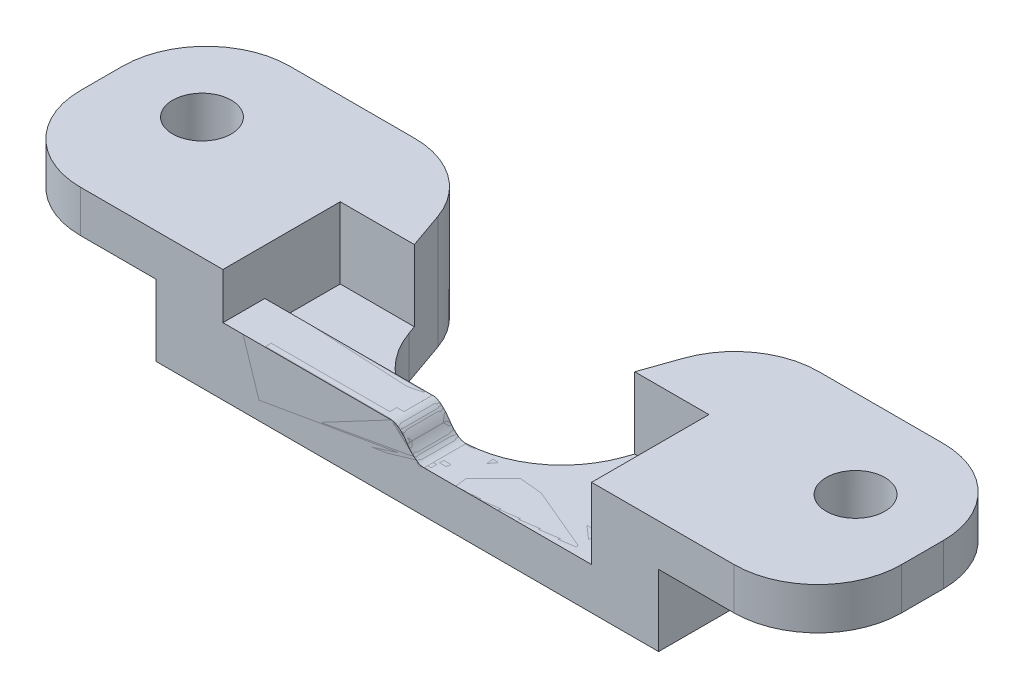
from build123d import *

# Parameters (mm, degrees)
EXTRUDE_1_DEPTH              = 5
EXTRUDE_2_DEPTH              = 5
SKETCH_3_R                   = 3.5
EXTRUDE_3_DEPTH              = 8.5
CUT_EXTRUDE_1_REACH          = 73.086
SKETCH_4_W                   = 19
SKETCH_4_H                   = 3.5
FILLET_5_R                   = 10
FILLET_6_R                   = 12
EXTRUDE_4_REACH              = 71.486
SKETCH_5_W                   = 5
SKETCH_5_H                   = 3
EXTRUDE_5_DEPTH              = 5
MM_TRANSITIONAL_0_AT_2_COUNT = 2
MM_TRANSITIONAL_0_AT_2_PITCH = 5
MM_TRANSITIONAL_0_AT_3_COUNT = 2
MM_TRANSITIONAL_0_AT_3_PITCH = 55
MM_TRANSITIONAL_0_AT_4_COUNT = 2
MM_TRANSITIONAL_0_AT_4_PITCH = 55.226805086


with BuildPart() as part:
    # 草图1 → 凸台-拉伸1 (new body)
    with BuildSketch(Plane.XY):
        with BuildLine():
            Line((0, 0), (0, 3))
            Line((0, 3), (15, 3))
            add(Edge.make_bspline(
                [(15, 3), (15.084020518, 3), (15.25421211, 2.98372688), (15.507820044, 2.911236723), (15.760073164, 2.791236035), (16.011273009, 2.624324039), (16.261740047, 2.410885471), (16.511438591, 2.15079543), (16.762076533, 1.845030055), (17, 1.5), (17.237923467, 1.154969945), (17.488561409, 0.84920457), (17.738259953, 0.589114529), (17.988726991, 0.375675961), (18.239926836, 0.208763965), (18.492179956, 0.088763277), (18.74578789, 0.01627312), (18.915979482, 0), (19, 0)],
                knots=[0, 0, 0, 0, 0.048331255, 0.098318483, 0.151463082, 0.209019894, 0.271980496, 0.341104305, 0.416965872, 0.5, 0.583034128, 0.658895695, 0.728019504, 0.790980106, 0.848536918, 0.901681517, 0.951668745, 1, 1, 1, 1], degree=3))
            Line((19, 0), (34, 0))
            Line((34, 0), (34, -5))
            Line((34, -5), (0, -5))
            Line((0, -5), (0, 0))
        make_face()
    extrude(amount=EXTRUDE_1_DEPTH)

    # 草图2 → 凸台-拉伸2 (add)
    with BuildSketch(Plane(origin=(0, 0, 0), x_dir=(1, 0, 0), z_dir=(0, 1, 0))):
        Polygon((-13, 20), (0, 20), (7, 0), (27, 0), (34, 20), (47, 20), (47, -5), (-13, -5), align=None)
    extrude(amount=-EXTRUDE_2_DEPTH)

    # 草图3 → 凸台-拉伸3 (add)
    with BuildSketch(Plane(origin=(0, 0, 0), x_dir=(1, 0, 0), z_dir=(0, 1, 0))):
        Polygon((-32, 20), (0, 20), (3.85, 9), (-5, 9), (-5, -5), (-32, -5), align=None)
        with Locations(Location((-22, 9.5, 0), (0, 0, 270))):
            Circle(SKETCH_3_R, mode=Mode.SUBTRACT)
        Polygon((30.15, 9), (34, 20), (66, 20), (66, -5), (39, -5), (39, 9), align=None)
        with Locations(Location((56, 9.5, 0), (0, 0, 90))):
            Circle(SKETCH_3_R, mode=Mode.SUBTRACT)
    extrude(amount=EXTRUDE_3_DEPTH)

    # 草图4 → 切除-拉伸1 (cut, up to next)
    with BuildSketch(Plane.XY.offset(5), mode=Mode.PRIVATE) as cut_extrude_1_sk1:
        with Locations((-22.5, 1.75)):
            Rectangle(SKETCH_4_W, SKETCH_4_H)
    cut_extrude_1_tool1 = extrude(cut_extrude_1_sk1.sketch, amount=-CUT_EXTRUDE_1_REACH, mode=Mode.PRIVATE) & part.part
    # 草图4 → 切除-拉伸1 (cut, up to next)
    with BuildSketch(Plane.XY.offset(5), mode=Mode.PRIVATE) as cut_extrude_1_sk2:
        with Locations((56.5, 1.75)):
            Rectangle(SKETCH_4_W, SKETCH_4_H)
    cut_extrude_1_tool2 = extrude(cut_extrude_1_sk2.sketch, amount=-CUT_EXTRUDE_1_REACH, mode=Mode.PRIVATE) & part.part
    add(cut_extrude_1_tool1.solids().sort_by_distance((-22.5, 1.75, 5))[0], mode=Mode.SUBTRACT)
    add(cut_extrude_1_tool2.solids().sort_by_distance((56.5, 1.75, 5))[0], mode=Mode.SUBTRACT)

    # 圆角5
    fillet_5_edges = [part.edges().sort_by_distance(p)[0] for p in [
        (0, 1.75, -20),
        (34, 1.75, -20),
        (-32, 6, -20),
        (-32, 6, 5),
        (66, 6, 5),
        (66, 6, -20),
    ]]
    fillet(fillet_5_edges, radius=FILLET_5_R)

    # 圆角6
    fillet_6_edges = [part.edges().sort_by_distance(p)[0] for p in [
        (7, -2.5, 0),
        (27, -2.5, 0),
    ]]
    fillet(fillet_6_edges, radius=FILLET_6_R)

    # 草图5 → 凸台-拉伸4 (add, up to next)
    with BuildSketch(Plane.ZY, mode=Mode.PRIVATE) as extrude_4_sk1:
        with Locations((2.5, 1.5)):
            Rectangle(SKETCH_5_W, SKETCH_5_H)
    extrude_4_tool1 = extrude(extrude_4_sk1.sketch, amount=EXTRUDE_4_REACH, mode=Mode.PRIVATE) - part.part
    add(extrude_4_tool1.solids().sort_by_distance((0, 1.5, 2.5))[0])

    # 草图9 → 大小mm Transitional 暗销孔0 (revolve, cut)
    with BuildSketch(Plane(origin=(44.5, -5, -7.000000033), x_dir=(0, 0, -1), z_dir=(1, 0, 0))):
        Polygon((0, 0), (0, 5.600860619), (1, 5), (1, 0), align=None)
    mm_transitional_0 = revolve(axis=Axis((44.5, -11.35, -7.000000033), (0, 1, 0)), mode=Mode.SUBTRACT)

    # 大小mm Transitional 暗销孔0 at 2: 大小mm Transitional 暗销孔0 ×2
    with Locations(*[(0, 0, -i * MM_TRANSITIONAL_0_AT_2_PITCH) for i in range(1, MM_TRANSITIONAL_0_AT_2_COUNT)]):
        add(mm_transitional_0, mode=Mode.SUBTRACT)

    # 大小mm Transitional 暗销孔0 at 3: 大小mm Transitional 暗销孔0 ×2
    with Locations(*[(-i * MM_TRANSITIONAL_0_AT_3_PITCH, 0, 0) for i in range(1, MM_TRANSITIONAL_0_AT_3_COUNT)]):
        add(mm_transitional_0, mode=Mode.SUBTRACT)

    # 大小mm Transitional 暗销孔0 at 4: 大小mm Transitional 暗销孔0 ×2
    with Locations(*[Vector(-0.9958932064677039, 0, -0.09053574604251886) * (i * MM_TRANSITIONAL_0_AT_4_PITCH) for i in range(1, MM_TRANSITIONAL_0_AT_4_COUNT)]):
        add(mm_transitional_0, mode=Mode.SUBTRACT)


with BuildPart() as body_2:
    # 草图7 → 凸台-拉伸5 (new body)
    with BuildSketch(Plane.XY):
        with BuildLine():
            add(Edge.make_bspline(
                [(0, -5), (11.333333333, -5), (22.666666667, -5), (34, -5), (34.75, -5), (35.5, -5), (36.25, -5), (36.333333333, -5), (36.5, -5), (36.75, -5), (36.916666667, -5), (37, -5), (37.085177062, -5), (37.255531185, -5), (37.511374058, -4.951599022), (37.67635735, -4.908276535), (37.757529961, -4.882466864), (40.584958925, -3.983456605), (40.584958925, -1.016543395), (37.757529961, -0.117533136), (37.67635735, -0.091723465), (37.511374058, -0.048400978), (37.255531185, 0), (37.085177062, 0), (37, 0), (36.916666667, 0), (36.75, 0), (36.5, 0), (36.333333333, 0), (36.25, 0), (35.5, 0), (34.75, 0), (34, 0), (29.423914321, 0), (24.847828642, 0), (20.271742963, 0), (20.129177345, 0), (19.844046109, 0), (19.416349256, 0), (19.13121802, 0), (18.988652402, 0), (18.899425687, 0), (18.720972257, 0), (18.443548085, 0.080405029), (18.292751559, 0.175830572), (18.217353296, 0.223543343), (18.172514092, 0.251918038), (18.082835683, 0.308667427), (17.956306563, 0.406511786), (17.874611554, 0.474305988), (17.834660313, 0.509228415), (17.805986227, 0.534293186), (17.68905163, 0.640370713), (17.488561409, 0.84920457), (17.237923467, 1.154969945), (17, 1.5), (16.762076533, 1.845030055), (16.511438591, 2.15079543), (16.31094837, 2.359629287), (16.194013773, 2.465706814), (16.165339687, 2.490771585), (16.125388446, 2.525694012), (16.043693437, 2.593488214), (15.917164317, 2.691332573), (15.827485908, 2.748081962), (15.782646704, 2.776456657), (15.707248441, 2.824169428), (15.556451915, 2.919594971), (15.279027743, 3), (15.100574313, 3), (15.011347598, 3), (14.86878198, 3), (14.583650744, 3), (14.155953891, 3), (13.870822655, 3), (13.728257037, 3), (9.152171358, 3), (4.576085679, 3), (0, 3), (-0.75, 3), (-1.5, 3), (-2.25, 3), (-2.333333333, 3), (-2.5, 3), (-2.75, 3), (-2.916666667, 3), (-3, 3), (-3.085382499, 3), (-3.256147498, 3), (-3.512422936, 2.969801398), (-3.681082298, 2.942514055), (-3.764889213, 2.926187017), (-9.340137732, 1.840032069), (-9.340137732, -3.840032069), (-3.764889213, -4.926187017), (-3.681082298, -4.942514055), (-3.512422936, -4.969801398), (-3.256147498, -5), (-3.085382499, -5), (-3, -5), (-2.916666667, -5), (-2.75, -5), (-2.5, -5), (-2.333333333, -5), (-2.25, -5), (-1.5, -5), (-0.75, -5), (0, -5)],
                knots=[0, 0, 0, 0, 0.350984847, 0.350984847, 0.350984847, 0.374211786, 0.374211786, 0.374211786, 0.376792557, 0.379373328, 0.381954099, 0.381954099, 0.381954099, 0.384591968, 0.387229838, 0.389867708, 0.389867708, 0.389867708, 0.439056518, 0.439056518, 0.439056518, 0.441694388, 0.444332258, 0.446970127, 0.446970127, 0.446970127, 0.449550898, 0.452131669, 0.45471244, 0.45471244, 0.45471244, 0.477939379, 0.477939379, 0.477939379, 0.619657326, 0.619657326, 0.619657326, 0.624072476, 0.628487627, 0.632902777, 0.632902777, 0.632902777, 0.635666062, 0.638429346, 0.641192631, 0.641192631, 0.641192631, 0.642835951, 0.644479271, 0.646122591, 0.646122591, 0.646122591, 0.647302046, 0.651011173, 0.655081842, 0.659537385, 0.663992927, 0.668063596, 0.671772723, 0.672952178, 0.672952178, 0.672952178, 0.674595498, 0.676238818, 0.677882138, 0.677882138, 0.677882138, 0.680645423, 0.683408707, 0.686171992, 0.686171992, 0.686171992, 0.690587142, 0.695002293, 0.699417443, 0.699417443, 0.699417443, 0.84113539, 0.84113539, 0.84113539, 0.864362329, 0.864362329, 0.864362329, 0.8669431, 0.869523871, 0.872104642, 0.872104642, 0.872104642, 0.874748874, 0.877393106, 0.880037338, 0.880037338, 0.880037338, 0.961098053, 0.961098053, 0.961098053, 0.963742285, 0.966386517, 0.969030749, 0.969030749, 0.969030749, 0.97161152, 0.974192291, 0.976773062, 0.976773062, 0.976773062, 1, 1, 1, 1], degree=3, weights=[1, 1, 1, 1, 1, 1, 1, 1, 1, 1, 1, 1, 1, 1, 1, 1, 1, 0.535341323, 0.535341323, 1, 1, 1, 1, 1, 1, 1, 1, 1, 1, 1, 1, 1, 1, 1, 1, 1, 1, 1, 1, 1, 1, 1, 1, 1, 1, 1, 1, 1, 1, 1, 1, 1, 1, 1, 1, 1, 1, 1, 1, 1, 1, 1, 1, 1, 1, 1, 1, 1, 1, 1, 1, 1, 1, 1, 1, 1, 1, 1, 1, 1, 1, 1, 1, 1, 1, 1, 1, 1, 1, 1, 1, 1, 0.460814869, 0.460814869, 1, 1, 1, 1, 1, 1, 1, 1, 1, 1, 1, 1, 1, 1]))
        make_face()
    extrude(amount=EXTRUDE_5_DEPTH)


solid = Compound([part.part, body_2.part])
